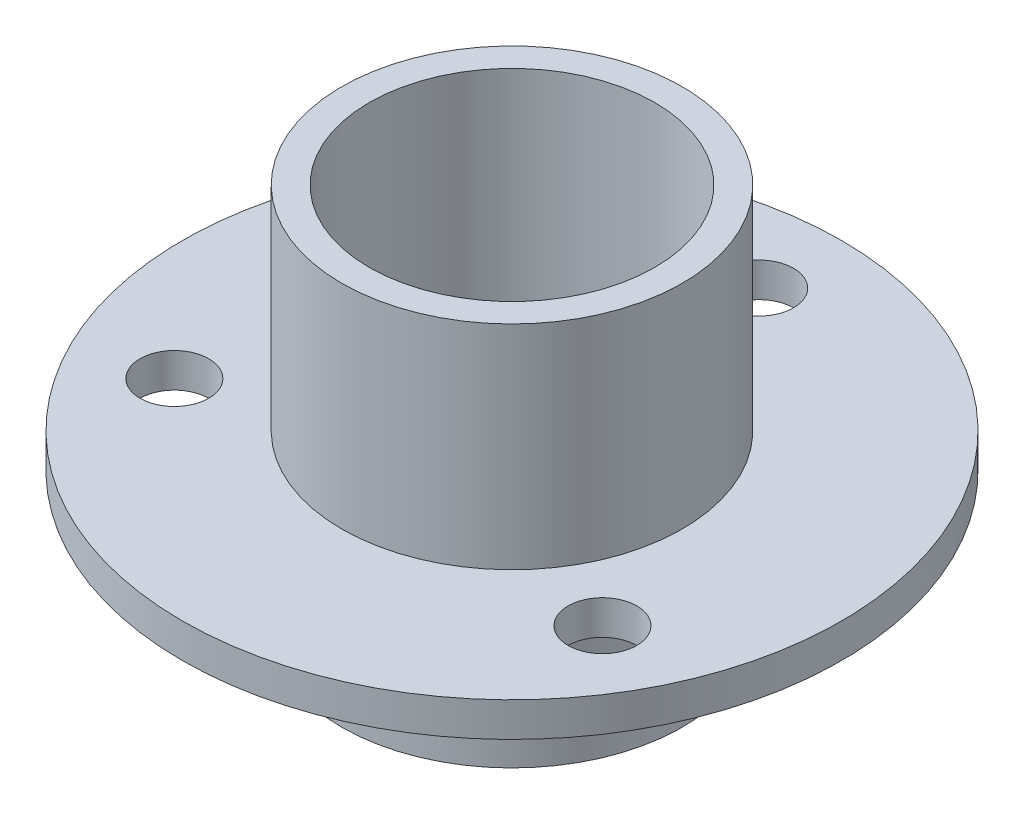
from build123d import *

# Parameters (mm, degrees)
SKETCH1_R           = 6.2
SKETCH1_R_2         = 5.2
BOSS_EXTRUDE1_DEPTH = 14
SKETCH2_R           = 12
SKETCH2_R_2         = 1.25
SKETCH2_R_3         = 5.2
BOSS_EXTRUDE2_DEPTH = 1.25


with BuildPart() as part:
    # Sketch1 → Boss-Extrude1 (new body)
    with BuildSketch(Plane(origin=(0, 0, 0), x_dir=(1, 0, 0), z_dir=(0, 1, 0))):
        Circle(SKETCH1_R)
        Circle(SKETCH1_R_2, mode=Mode.SUBTRACT)
    extrude(amount=BOSS_EXTRUDE1_DEPTH)

    # Sketch2 → Boss-Extrude2 (add)
    with BuildSketch(Plane(origin=(0, 4.999999906, 0), x_dir=(-1, 0, 0), z_dir=(0, 1, 0))):
        Circle(SKETCH2_R)
        with Locations((0, -9)):
            Circle(SKETCH2_R_2, mode=Mode.SUBTRACT)
        with Locations((-7.794228634, 4.5)):
            Circle(SKETCH2_R_2, mode=Mode.SUBTRACT)
        with Locations((7.794228634, 4.5)):
            Circle(SKETCH2_R_2, mode=Mode.SUBTRACT)
        Circle(SKETCH2_R_3, mode=Mode.SUBTRACT)
    extrude(amount=BOSS_EXTRUDE2_DEPTH)


solid = part.part
